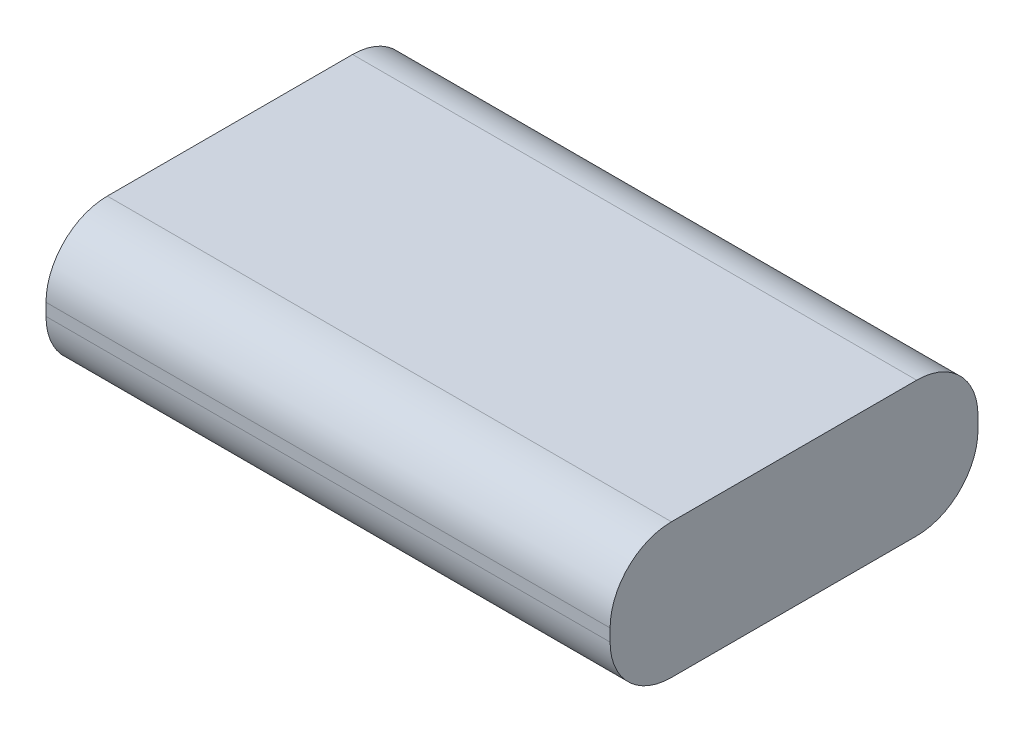
from build123d import *

# Parameters (mm, degrees)
SKETCH1_W           = 92
SKETCH1_H           = 60
BOSS_EXTRUDE1_DEPTH = 22
FILLET1_R           = 10


with BuildPart() as part:
    # Sketch1 → Boss-Extrude1 (new body)
    with BuildSketch(Plane(origin=(0, 0, 0), x_dir=(1, 0, 0), z_dir=(0, 1, 0))):
        Rectangle(SKETCH1_W, SKETCH1_H)
    extrude(amount=BOSS_EXTRUDE1_DEPTH)

    # Fillet1
    fillet1_edges = [part.edges().sort_by_distance(p)[0] for p in [
        (0, 22, 30),
        (0, 0, 30),
        (0, 0, -30),
        (0, 22, -30),
    ]]
    fillet(fillet1_edges, radius=FILLET1_R)


solid = part.part
